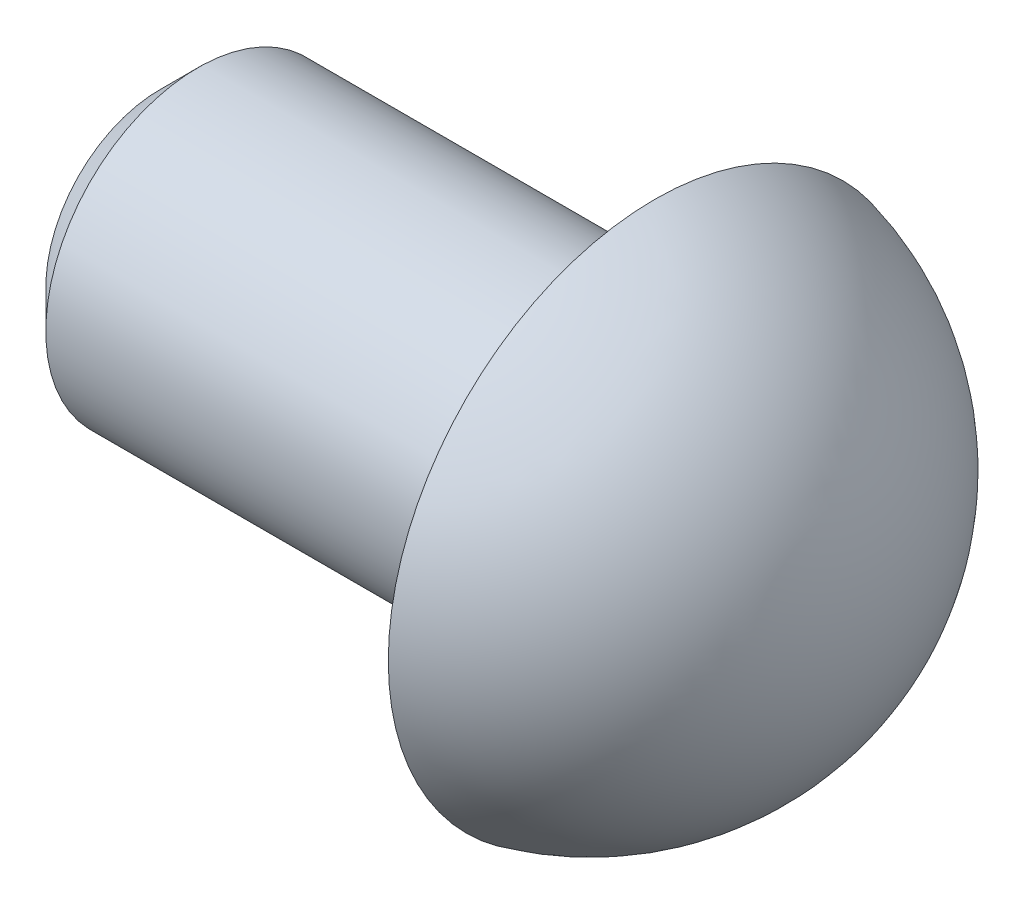
from build123d import *

# Parameters (mm, degrees)
SKETCH1_R           = 2
BOSS_EXTRUDE1_DEPTH = 6.5
CHAMFER1_SIZE       = 0.5


with BuildPart() as part:
    # Sketch1 → Boss-Extrude1 (new body)
    with BuildSketch(Plane(origin=(0, 0, 0), x_dir=(0, 0, -1), z_dir=(1, 0, 0))):
        Circle(SKETCH1_R)
    extrude(amount=-BOSS_EXTRUDE1_DEPTH)

    # Sketch2 → Revolve1 (revolve)
    with BuildSketch(Plane(origin=(0, 0, 0), x_dir=(1, 0, 0), z_dir=(0, 1, 0))):
        with BuildLine():
            Line((2.757385023, 0), (0, 0))
            Line((0, 0), (0, 3.5))
            ThreePointArc((0, 3.5), (1.985229955, 2.227844932), (2.757385023, 0))
        make_face()
    revolve(axis=Axis((-2.546955696, 0, 0), (1, 0, 0)))

    # Chamfer1
    chamfer1_edges = [part.edges().sort_by_distance(p)[0] for p in [
        (-6.5, 0, 2),
    ]]
    chamfer(chamfer1_edges, length=CHAMFER1_SIZE)


solid = part.part
